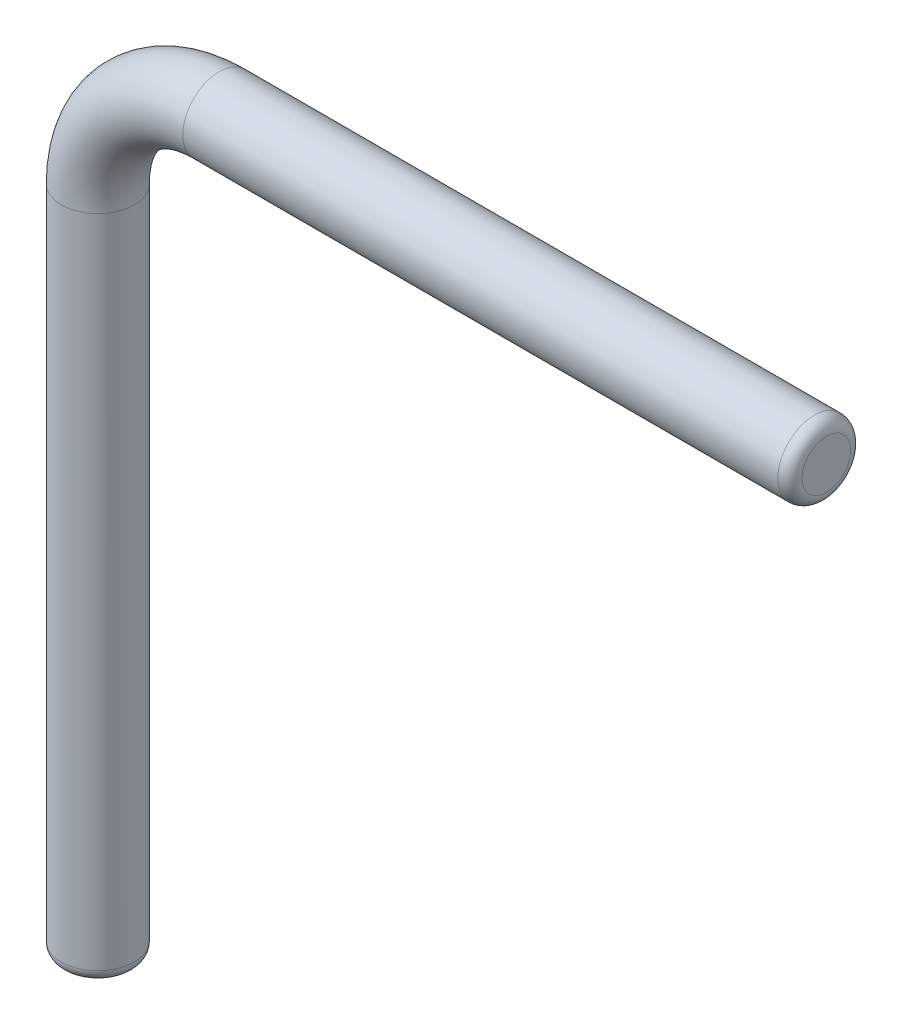
from build123d import *

# Parameters (mm, degrees)
SKETCH4_R = 0.3
FILLET1_R = 0.1


with BuildPart() as part:
    # Sweep1: sweep along a path in Sketch3
    with BuildLine(Plane.XY) as sweep1_path:
        Line((0, 0), (0, 5.5))
        ThreePointArc((0, 5.5), (0.292893219, 6.207106781), (1, 6.5))
        Line((1, 6.5), (6, 6.5))
    # Sketch4 → Sweep1 (sweep)
    with BuildSketch(Plane(origin=(0, 0, 0), x_dir=(1, 0, 0), z_dir=(0, 1, 0))):
        Circle(SKETCH4_R)
    sweep(path=sweep1_path.line)

    # Fillet1
    fillet1_edges = [part.edges().sort_by_distance(p)[0] for p in [
        (-0.3, 0, 0),
        (6, 6.8, 0),
    ]]
    fillet(fillet1_edges, radius=FILLET1_R)


solid = part.part
